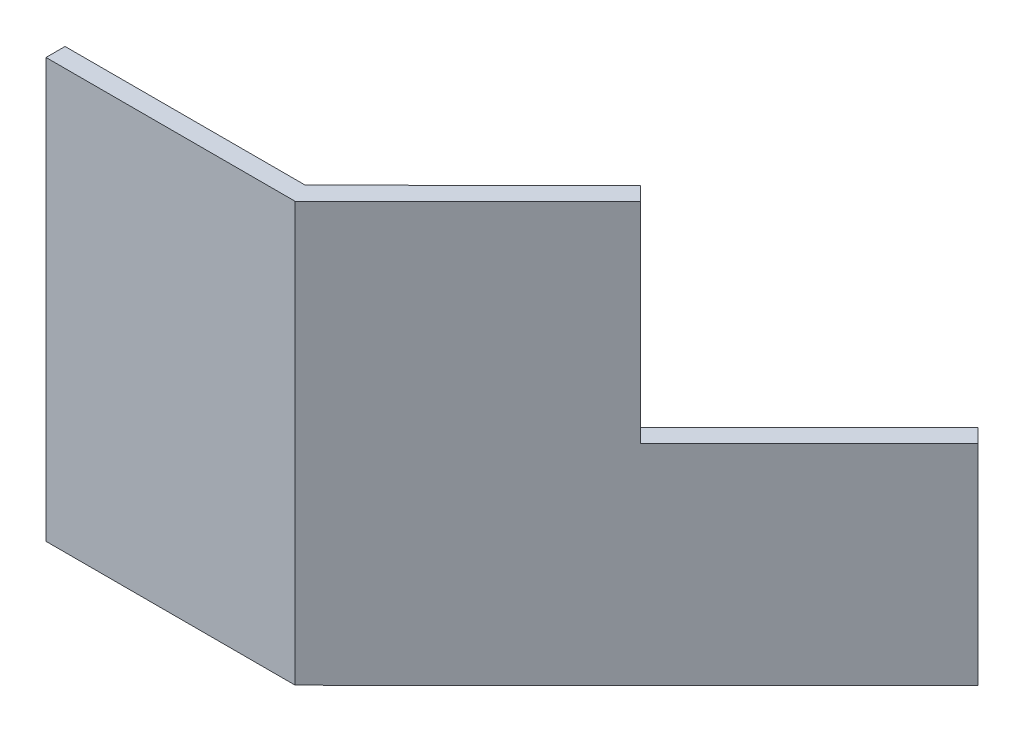
from build123d import *

# Parameters (mm, degrees)
BOSS_EXTRUDE1_DEPTH = 7.62
CUT_EXTRUDE2_DEPTH  = 3.81


with BuildPart() as part:
    # Sketch1 → Boss-Extrude1 (new body)
    with BuildSketch(Plane(origin=(0, 0, 0), x_dir=(1, 0, 0), z_dir=(0, 1, 0))):
        Polygon((-0.253590848, 0), (-4.623419976, 0), (-4.623419976, -0.346366729), (-0.092515757, -0.346366729), (6.119785938, 5.855927972), (5.86619509, 6.109927972), align=None)
    extrude(amount=BOSS_EXTRUDE1_DEPTH)

    # Sketch3 → Cut-Extrude2 (cut)
    with BuildSketch(Plane(origin=(0, 7.62, 0), x_dir=(1, 0, 0), z_dir=(0, 1, 0))):
        Polygon((6.119785938, 5.855927972), (5.86619509, 6.109927972), (2.793767925, 3.042449981), (3.047358773, 2.788449981), align=None)
    extrude(amount=-CUT_EXTRUDE2_DEPTH, mode=Mode.SUBTRACT)


solid = part.part
